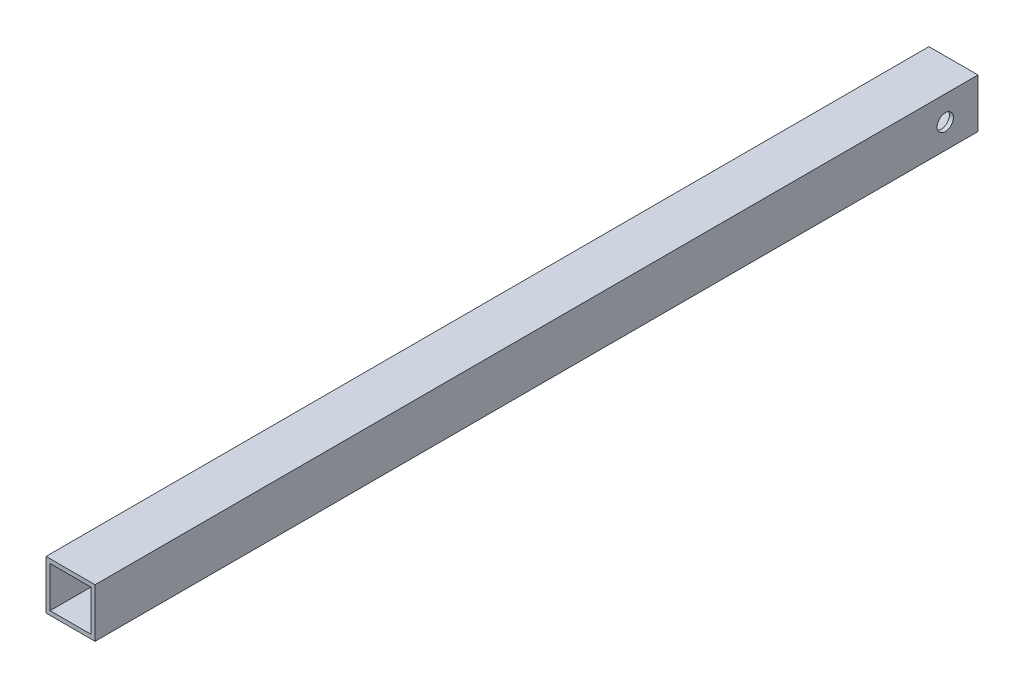
from build123d import *

# Parameters (mm, degrees)
SKETCH1_W           = 76.2
SKETCH1_H           = 76.2
SKETCH1_W_2         = 63.5
SKETCH1_H_2         = 63.5
BOSS_EXTRUDE1_DEPTH = 1371.6
SKETCH2_R           = 12.7
CUT_EXTRUDE1_DEPTH  = 77.2


with BuildPart() as part:
    # Sketch1 → Boss-Extrude1 (new body)
    with BuildSketch(Plane.XY):
        Rectangle(SKETCH1_W, SKETCH1_H)
        Rectangle(SKETCH1_W_2, SKETCH1_H_2, mode=Mode.SUBTRACT)
    extrude(amount=BOSS_EXTRUDE1_DEPTH)

    # Sketch2 → Cut-Extrude1 (cut, through all)
    with BuildSketch(Plane(origin=(38.1, 0, 0), x_dir=(0, 0, -1), z_dir=(1, 0, 0))):
        with Locations((-50.8, 0)):
            Circle(SKETCH2_R)
    extrude(amount=-CUT_EXTRUDE1_DEPTH, mode=Mode.SUBTRACT)


solid = part.part
